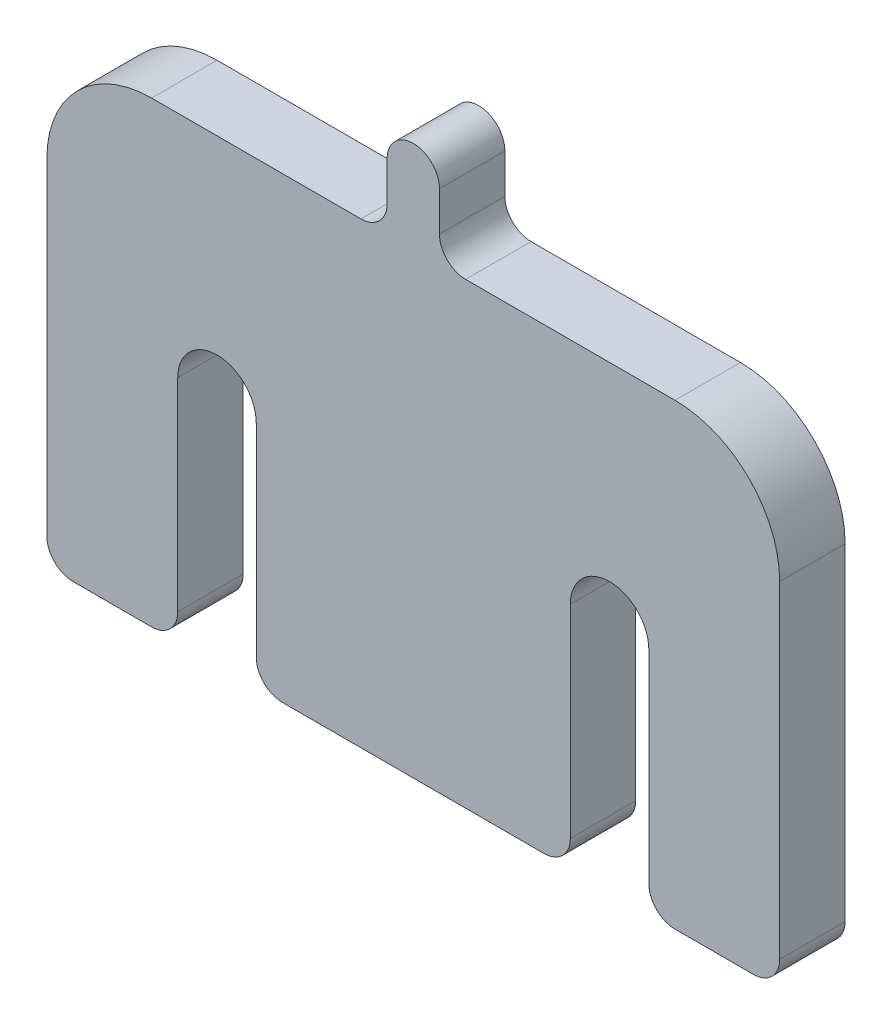
from build123d import *

# Parameters (mm, degrees)
SZKIC1_R                    = 2
DODANIE_WYCI_GNI_CIE1_DEPTH = 5
ZAOKR_GLENIE1_R             = 2
ZAOKR_GLENIE2_R             = 8


with BuildPart() as part:
    # Szkic1 → Dodanie-wyciągnięcie1 (new body)
    with BuildSketch(Plane.XY):
        with BuildLine():
            ThreePointArc((12, 0), (15, 3), (18, 0))
            Line((18, 0), (18, -17.5))
            Line((18, -17.5), (28, -17.5))
            Line((28, -17.5), (28, 17.5))
            Line((28, 17.5), (2, 17.5))
            Line((2, 17.5), (-2, 17.5))
            Line((-2, 17.5), (-28, 17.5))
            Line((-28, 17.5), (-28, -17.5))
            Line((-28, -17.5), (-18, -17.5))
            Line((-18, -17.5), (-18, 0))
            ThreePointArc((-18, 0), (-15, 3), (-12, 0))
            Line((-12, 0), (-12, -17.5))
            Line((-12, -17.5), (12, -17.5))
            Line((12, -17.5), (12, 0))
        make_face()
        with BuildLine():
            Line((-2, 17.5), (2, 17.5))
            Line((2, 17.5), (2, 22.5))
            ThreePointArc((2, 22.5), (0, 20.5), (-2, 22.5))
            Line((-2, 22.5), (-2, 17.5))
        make_face()
        with Locations((0, 22.5)):
            Circle(SZKIC1_R)
    extrude(amount=DODANIE_WYCI_GNI_CIE1_DEPTH)

    # Zaokrąglenie1
    zaokr_glenie1_edges = [part.edges().sort_by_distance(p)[0] for p in [
        (12, -17.5, 2.5),
        (-12, -17.5, 2.5),
        (-18, -17.5, 2.5),
        (-28, -17.5, 2.5),
        (-2, 17.5, 2.5),
        (2, 17.5, 2.5),
        (28, -17.5, 2.5),
        (18, -17.5, 2.5),
    ]]
    fillet(zaokr_glenie1_edges, radius=ZAOKR_GLENIE1_R)

    # Zaokrąglenie2
    zaokr_glenie2_edges = [part.edges().sort_by_distance(p)[0] for p in [
        (-28, 17.5, 2.5),
        (28, 17.5, 2.5),
    ]]
    fillet(zaokr_glenie2_edges, radius=ZAOKR_GLENIE2_R)


solid = part.part
